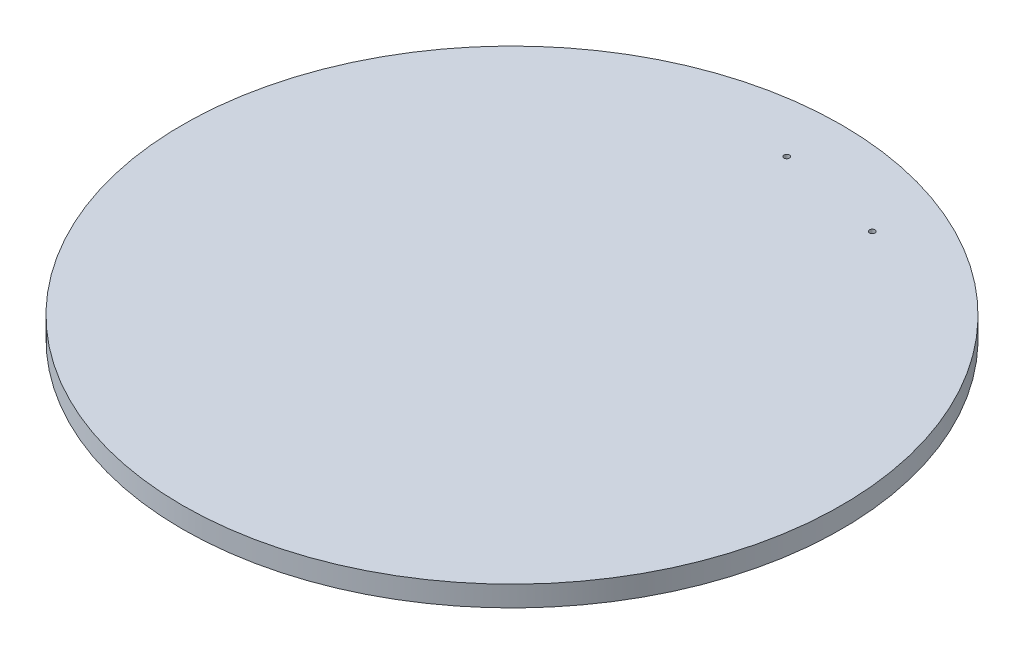
from build123d import *

# Parameters (mm, degrees)
SKETCH2_R           = 304.8
BOSS_EXTRUDE1_DEPTH = 19.05
SKETCH3_R           = 2.54
CUT_EXTRUDE1_DEPTH  = 20.05


with BuildPart() as part:
    # Sketch2 → Boss-Extrude1 (new body)
    with BuildSketch(Plane(origin=(0, 0, 0), x_dir=(1, 0, 0), z_dir=(0, 1, 0))):
        Circle(SKETCH2_R)
    extrude(amount=BOSS_EXTRUDE1_DEPTH)

    # Sketch3 → Cut-Extrude1 (cut, through all)
    with BuildSketch(Plane(origin=(0, 19.05, 0), x_dir=(1, 0, 0), z_dir=(0, 1, 0))):
        with Locations((0, 254)):
            Circle(SKETCH3_R)
        with Locations((99.547263147, 233.68)):
            Circle(SKETCH3_R)
    extrude(amount=-CUT_EXTRUDE1_DEPTH, mode=Mode.SUBTRACT)


solid = part.part
